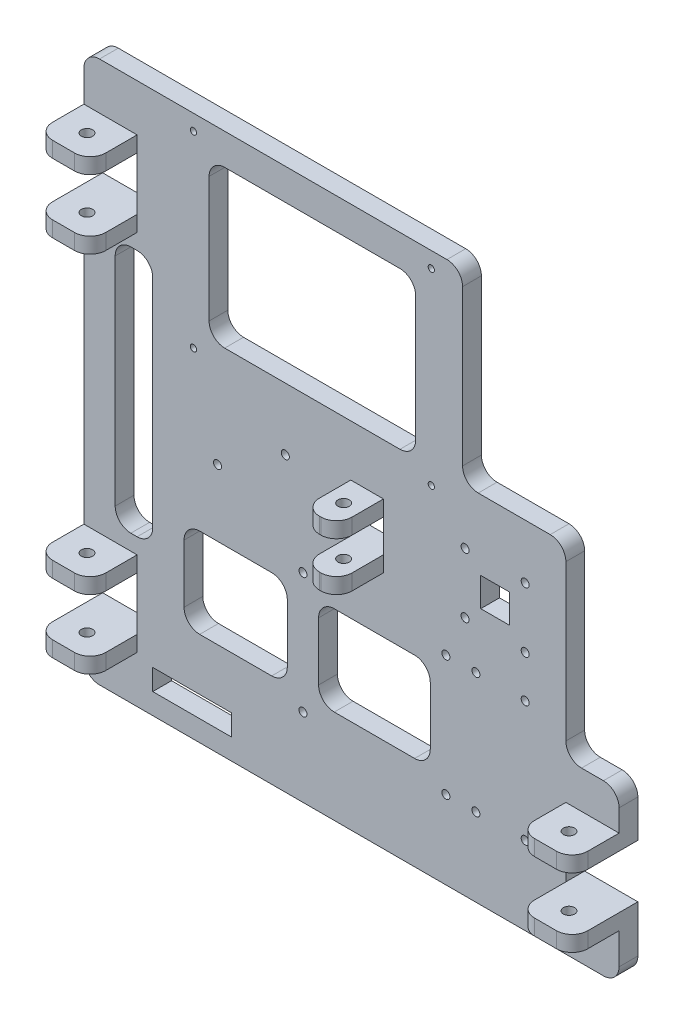
from build123d import *

# Parameters (mm, degrees)
SKETCH1_W           = 13.26865531
SKETCH1_H           = 13.268655309
BOSS_EXTRUDE1_DEPTH = 7.62
SKETCH5_R           = 1.27
CUT_EXTRUDE3_DEPTH  = 8.62
CUT_EXTRUDE5_REACH  = 9.62
SKETCH9_W           = 32
SKETCH9_H           = 8.5
SKETCH10_R          = 1.625
CUT_EXTRUDE6_DEPTH  = 8.62
SKETCH13_W          = 21.59
SKETCH13_H          = 6.35
SKETCH13_W_2        = 13.26865531
BOSS_EXTRUDE2_DEPTH = 19.05
SKETCH14_R          = 2.286
CUT_EXTRUDE7_DEPTH  = 201.924200001
SKETCH15_R          = 2.286
CUT_EXTRUDE8_DEPTH  = 123.971427656
SKETCH8_R           = 1.6250031
CUT_EXTRUDE9_DEPTH  = 27.67
SKETCH19_R          = 2.286
CUT_EXTRUDE13_DEPTH = 201.924200001
CUT_EXTRUDE14_REACH = 28.67
SKETCH20_R          = 1.625
SKETCH22_W          = 11.684
SKETCH22_H          = 11.684
SKETCH22_W_2        = 45.3
SKETCH22_H_2        = 36.3
SKETCH22_W_3        = 83.82
SKETCH22_H_3        = 63.500000001
SKETCH22_W_4        = 41.91
SKETCH22_W_5        = 15.24
SKETCH22_H_4        = 100.5942
CUT_EXTRUDE15_DEPTH = 27.67
SKETCH24_R          = 1.625
CUT_EXTRUDE16_DEPTH = 27.67
FILLET2_R           = 6.35
FILLET4_R           = 6.35
FILLET5_R           = 6.35


with BuildPart() as part:
    # Sketch1 → Boss-Extrude1 (new body)
    with BuildSketch(Plane(origin=(0, 0, 0), x_dir=(-1, 0, 0), z_dir=(0, 0, 1))):
        Polygon((0, -67.741156164), (0, -193.735356164), (-21.59, -193.735356164), (-21.59, -215.325356165), (0, -215.325356165), (0, -240.725356165), (-153.67, -240.725356165), (-153.67, -165.028256165), (-195.58, -165.028256165), (-195.58, -89.331156165), (-217.17, -89.331156165), (-217.17, -67.741156164), (-195.58, -67.741156164), (-195.58, -46.151156164), (-217.17, -46.151156164), (-217.17, -20.751156164), (0, -20.751156164), (0, -46.151156164), (-21.59, -46.151156164), (-21.59, -67.741156164), align=None)
        with Locations((-114.925672351, -130.738256165)):
            Rectangle(SKETCH1_W, SKETCH1_H, mode=Mode.SUBTRACT)
    extrude(amount=BOSS_EXTRUDE1_DEPTH)

    # Sketch5 → Cut-Extrude3 (cut, through all)
    with BuildSketch(Plane.XY.offset(7.62)):
        with Locations((44.45, 234.375356165)):
            Circle(SKETCH5_R)
        with Locations((140.97, 234.375356165)):
            Circle(SKETCH5_R)
        with Locations((44.45, 158.175356164)):
            Circle(SKETCH5_R)
        with Locations((140.97, 158.175356164)):
            Circle(SKETCH5_R)
    extrude(amount=-CUT_EXTRUDE3_DEPTH, mode=Mode.SUBTRACT)

    # Sketch9 → Cut-Extrude5 (cut, up to next)
    with BuildSketch(Plane(origin=(0, 0, 0), x_dir=(-1, 0, 0), z_dir=(0, 0, -1)), mode=Mode.PRIVATE) as cut_extrude5_sk1:
        with Locations((-43.94, 33.467738164)):
            Rectangle(SKETCH9_W, SKETCH9_H)
    cut_extrude5_tool1 = extrude(cut_extrude5_sk1.sketch, amount=-CUT_EXTRUDE5_REACH, mode=Mode.PRIVATE) & part.part
    add(cut_extrude5_tool1.solids().sort_by_distance((43.94, 33.467738, 0))[0], mode=Mode.SUBTRACT)

    # Sketch10 → Cut-Extrude6 (cut, through all)
    with BuildSketch(Plane.XY.offset(7.62)):
        with Locations((179.07, 142.930256164)):
            Circle(SKETCH10_R)
        with Locations((179.07, 118.546256164)):
            Circle(SKETCH10_R)
        with Locations((154.686, 118.546256164)):
            Circle(SKETCH10_R)
        with Locations((154.686, 142.930256164)):
            Circle(SKETCH10_R)
    extrude(amount=-CUT_EXTRUDE6_DEPTH, mode=Mode.SUBTRACT)

    # Sketch13 → Boss-Extrude2 (add)
    with BuildSketch(Plane.XY.offset(7.62)):
        with Locations((10.795, 218.500356165)):
            Rectangle(SKETCH13_W, SKETCH13_H)
        with Locations((10.795, 190.560356164)):
            Rectangle(SKETCH13_W, SKETCH13_H)
        with Locations((10.795, 42.976156164)):
            Rectangle(SKETCH13_W, SKETCH13_H)
        with Locations((10.795, 70.916156164)):
            Rectangle(SKETCH13_W, SKETCH13_H)
        with Locations((114.925672351, 140.547583819)):
            Rectangle(SKETCH13_W_2, SKETCH13_H)
        with Locations((114.925672351, 120.92892851)):
            Rectangle(SKETCH13_W_2, SKETCH13_H)
        with Locations((206.375, 42.976156164)):
            Rectangle(SKETCH13_W, SKETCH13_H)
        with Locations((206.375, 70.916156164)):
            Rectangle(SKETCH13_W, SKETCH13_H)
    extrude(amount=BOSS_EXTRUDE2_DEPTH)

    # Sketch14 → Cut-Extrude7 (cut, through all)
    with BuildSketch(Plane.XZ.offset(-39.801156164)):
        with Locations((10.795, 17.145)):
            Circle(SKETCH14_R)
    extrude(amount=-CUT_EXTRUDE7_DEPTH, mode=Mode.SUBTRACT)

    # Sketch15 → Cut-Extrude8 (cut, through all)
    with BuildSketch(Plane.XZ.offset(-117.75392851)):
        with Locations((114.925672351, 17.145)):
            Circle(SKETCH15_R)
    extrude(amount=-CUT_EXTRUDE8_DEPTH, mode=Mode.SUBTRACT)

    # Sketch8 → Cut-Extrude9 (cut, through all)
    with BuildSketch(Plane(origin=(0, 0, 0), x_dir=(-1, 0, 0), z_dir=(0, 0, -1))):
        with Locations((-88.9, 52.501156164)):
            Circle(SKETCH8_R)
        with Locations((-146.9, 52.501156164)):
            Circle(SKETCH8_R)
        with Locations((-88.9, 101.501156164)):
            Circle(SKETCH8_R)
        with Locations((-146.9, 101.501156164)):
            Circle(SKETCH8_R)
    extrude(amount=-CUT_EXTRUDE9_DEPTH, mode=Mode.SUBTRACT)

    # Sketch19 → Cut-Extrude13 (cut, through all)
    with BuildSketch(Plane.XZ.offset(-39.801156164)):
        with Locations((206.375, 17.145)):
            Circle(SKETCH19_R)
    extrude(amount=-CUT_EXTRUDE13_DEPTH, mode=Mode.SUBTRACT)

    # Sketch20 → Cut-Extrude14 (cut, up to next)
    with BuildSketch(Plane(origin=(0, 0, 0), x_dir=(-1, 0, 0), z_dir=(0, 0, -1)), mode=Mode.PRIVATE) as cut_extrude14_sk1:
        with Locations((-81.741344696, 139.338256164)):
            Circle(SKETCH20_R)
    cut_extrude14_tool1 = extrude(cut_extrude14_sk1.sketch, amount=-CUT_EXTRUDE14_REACH, mode=Mode.PRIVATE) & part.part
    add(cut_extrude14_tool1.solids().sort_by_distance((81.741345, 139.338256, 0))[0], mode=Mode.SUBTRACT)
    # Sketch20 → Cut-Extrude14 (cut, up to next)
    with BuildSketch(Plane(origin=(0, 0, 0), x_dir=(-1, 0, 0), z_dir=(0, 0, -1)), mode=Mode.PRIVATE) as cut_extrude14_sk2:
        with Locations((-54.241344696, 122.138256164)):
            Circle(SKETCH20_R)
    cut_extrude14_tool2 = extrude(cut_extrude14_sk2.sketch, amount=-CUT_EXTRUDE14_REACH, mode=Mode.PRIVATE) & part.part
    add(cut_extrude14_tool2.solids().sort_by_distance((54.241345, 122.138256, 0))[0], mode=Mode.SUBTRACT)

    # Sketch22 → Cut-Extrude15 (cut, through all)
    with BuildSketch(Plane(origin=(0, 0, 0), x_dir=(-1, 0, 0), z_dir=(0, 0, -1))):
        with Locations((-166.878, 130.738256164)):
            Rectangle(SKETCH22_W, SKETCH22_H)
        with Locations((-117.9, 77.001156164)):
            Rectangle(SKETCH22_W_2, SKETCH22_H_2)
        with Locations((-92.71, 196.275356165)):
            Rectangle(SKETCH22_W_3, SKETCH22_H_3)
        with Locations((-61.595, 77.001156164)):
            Rectangle(SKETCH22_W_4, SKETCH22_H_2)
        with Locations((-20.32, 130.738256164)):
            Rectangle(SKETCH22_W_5, SKETCH22_H_4)
    extrude(amount=-CUT_EXTRUDE15_DEPTH, mode=Mode.SUBTRACT)

    # Sketch24 → Cut-Extrude16 (cut, through all)
    with BuildSketch(Plane(origin=(0, 0, 0), x_dir=(-1, 0, 0), z_dir=(0, 0, -1))):
        with Locations((-179.07, 101.501156164)):
            Circle(SKETCH24_R)
        with Locations((-159.07, 101.501156164)):
            Circle(SKETCH24_R)
        with Locations((-159.07, 52.501156164)):
            Circle(SKETCH24_R)
        with Locations((-179.07, 52.501156164)):
            Circle(SKETCH24_R)
    extrude(amount=-CUT_EXTRUDE16_DEPTH, mode=Mode.SUBTRACT)

    # Fillet2
    fillet2_edges = [part.edges().sort_by_distance(p)[0] for p in [
        (0, 218.500356165, 26.67),
        (21.59, 218.500356165, 26.67),
        (0, 190.560356164, 26.67),
        (21.59, 190.560356164, 26.67),
        (0, 42.976156164, 26.67),
        (21.59, 42.976156164, 26.67),
        (0, 70.916156164, 26.67),
        (21.59, 70.916156164, 26.67),
        (121.560000006, 120.92892851, 26.67),
        (108.291344696, 120.92892851, 26.67),
        (121.560000006, 140.547583819, 26.67),
        (108.291344696, 140.547583819, 26.67),
        (217.17, 70.916156164, 26.67),
        (195.58, 70.916156164, 26.67),
        (217.17, 42.976156164, 26.67),
        (195.58, 42.976156164, 26.67),
    ]]
    fillet(fillet2_edges, radius=FILLET2_R)

    # Fillet4
    fillet4_edges = [part.edges().sort_by_distance(p)[0] for p in [
        (0, 20.751156164, 3.81),
        (217.17, 20.751156164, 3.81),
        (217.17, 89.331156165, 3.81),
        (195.58, 89.331156165, 3.81),
        (195.58, 165.028256165, 3.81),
        (153.67, 165.028256165, 3.81),
        (153.67, 240.725356165, 3.81),
        (0, 240.725356165, 3.81),
    ]]
    fillet(fillet4_edges, radius=FILLET4_R)

    # Fillet5
    fillet5_edges = [part.edges().sort_by_distance(p)[0] for p in [
        (27.94, 80.441156164, 3.81),
        (27.94, 181.035356164, 3.81),
        (12.7, 181.035356164, 3.81),
        (12.7, 80.441156164, 3.81),
        (82.55, 58.851156164, 3.81),
        (82.55, 95.151156164, 3.81),
        (40.64, 95.151156164, 3.81),
        (40.64, 58.851156164, 3.81),
        (134.62, 164.525356164, 3.81),
        (134.62, 228.025356165, 3.81),
        (50.8, 228.025356165, 3.81),
        (50.8, 164.525356164, 3.81),
        (140.55, 58.851156164, 3.81),
        (140.55, 95.151156164, 3.81),
        (95.25, 95.151156164, 3.81),
        (95.25, 58.851156164, 3.81),
    ]]
    fillet(fillet5_edges, radius=FILLET5_R)


solid = part.part
